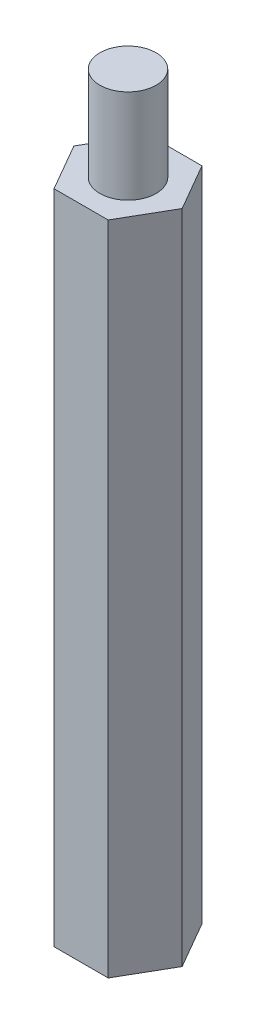
from build123d import *

# Parameters (mm, degrees)
EXTRUDE_1_DEPTH = 35
SKETCH_2_R      = 1.5
EXTRUDE_2_DEPTH = 5


with BuildPart() as part:
    # 草圖1 → 填料-伸長1 (new body)
    with BuildSketch(Plane(origin=(0, 0, 0), x_dir=(1, 0, 0), z_dir=(0, 1, 0))):
        Polygon((2.886751346, 0), (1.443375673, 2.5), (-1.443375673, 2.5), (-2.886751346, 0), (-1.443375673, -2.5), (1.443375673, -2.5), align=None)
    extrude(amount=EXTRUDE_1_DEPTH)

    # 草圖2 → 填料-伸長2 (add)
    with BuildSketch(Plane(origin=(0, 35, 0), x_dir=(1, 0, 0), z_dir=(0, 1, 0))):
        Circle(SKETCH_2_R)
    extrude(amount=EXTRUDE_2_DEPTH)


solid = part.part
